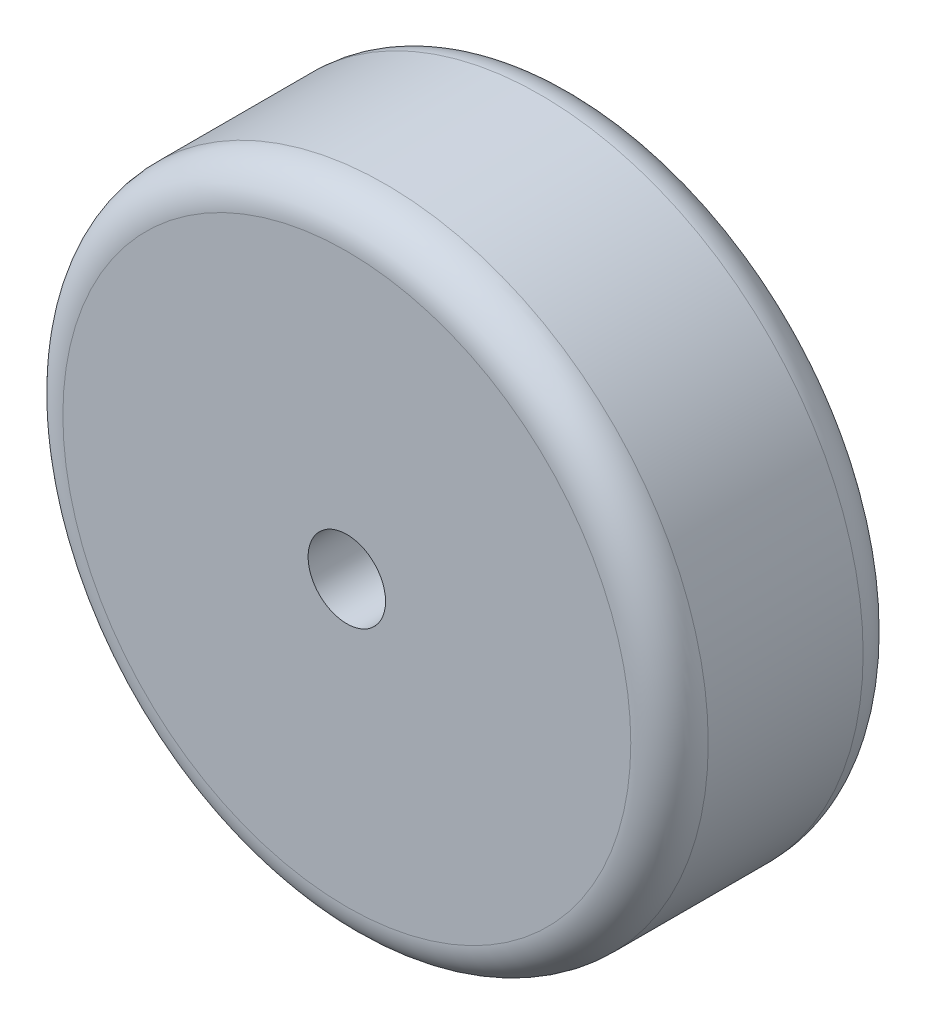
from build123d import *

# Parameters (mm, degrees)
SKETCH1_R           = 25
SKETCH1_R_2         = 3
BOSS_EXTRUDE1_DEPTH = 18
FILLET1_R           = 3


with BuildPart() as part:
    # Sketch1 → Boss-Extrude1 (new body)
    with BuildSketch(Plane.XY):
        Circle(SKETCH1_R)
        Circle(SKETCH1_R_2, mode=Mode.SUBTRACT)
    extrude(amount=BOSS_EXTRUDE1_DEPTH)

    # Fillet1
    fillet1_edges = [part.edges().sort_by_distance(p)[0] for p in [
        (-25, 0, 0),
        (-25, 0, 18),
    ]]
    fillet(fillet1_edges, radius=FILLET1_R)


solid = part.part
